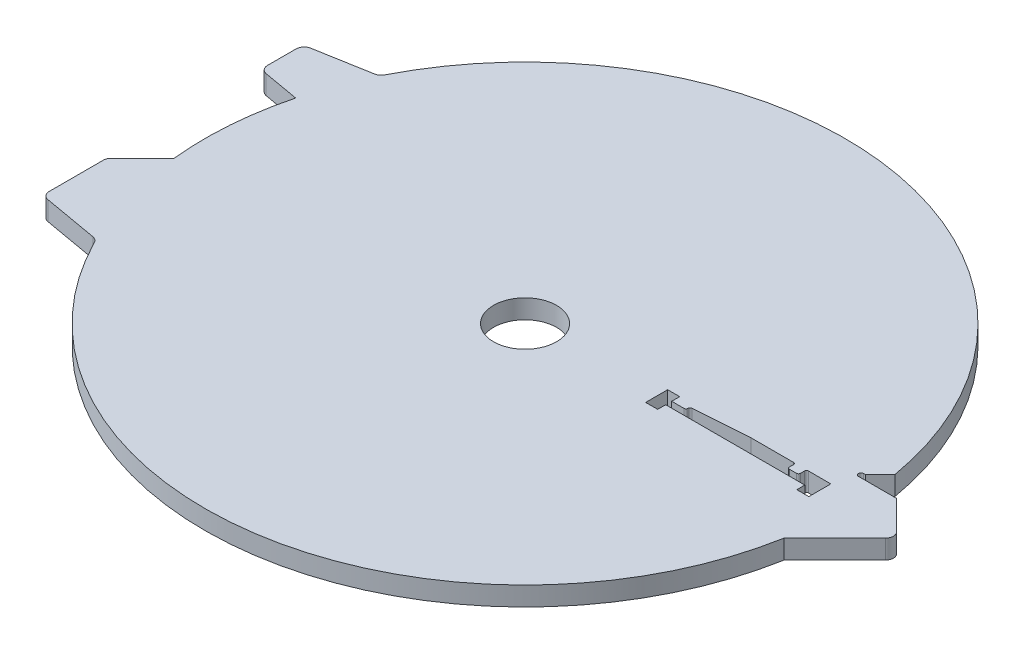
from build123d import *

# Parameters (mm, degrees)
SKETCH1_R           = 80
SKETCH1_R_2         = 7.875
BOSS_EXTRUDE1_DEPTH = 4.7625
CUT_EXTRUDE1_DEPTH  = 5.7625
BOSS_EXTRUDE2_DEPTH = 4.7625
CUT_EXTRUDE2_DEPTH  = 5.7625
CUT_EXTRUDE5_DEPTH  = 5.7625
FILLET1_R           = 2
SKETCH8_W           = 3
SKETCH8_H           = 5.5
CUT_EXTRUDE6_DEPTH  = 5.7625


with BuildPart() as part:
    # Sketch1 → Boss-Extrude1 (new body)
    with BuildSketch(Plane(origin=(0, 0, 0), x_dir=(1, 0, 0), z_dir=(0, 1, 0))):
        Circle(SKETCH1_R)
        Circle(SKETCH1_R_2, mode=Mode.SUBTRACT)
    extrude(amount=BOSS_EXTRUDE1_DEPTH)

    # Sketch2 → Cut-Extrude1 (cut, through all)
    with BuildSketch(Plane(origin=(0, 4.7625, 0), x_dir=(1, 0, 0), z_dir=(0, 1, 0))):
        with BuildLine():
            Line((34.2, 0), (70.8, 0))
            Line((70.8, 0), (70.8, 3))
            ThreePointArc((70.8, 3), (70.653553391, 3.353553391), (70.3, 3.5))
            Line((70.3, 3.5), (67.3, 3.5))
            ThreePointArc((67.3, 3.5), (66.946446609, 3.353553391), (66.8, 3))
            Line((66.8, 3), (66.8, 2))
            ThreePointArc((66.8, 2), (66.653553391, 1.646446609), (66.3, 1.5))
            Line((66.3, 1.5), (64.55, 1.5))
            ThreePointArc((64.55, 1.5), (64.196446609, 1.646446609), (64.05, 2))
            Line((64.05, 2), (64.05, 3))
            ThreePointArc((64.05, 3), (63.903553391, 3.353553391), (63.55, 3.5))
            Line((63.55, 3.5), (52.95, 3.5))
            Line((52.95, 3.5), (39.164998359, 2.532631464))
            ThreePointArc((39.164998359, 2.532631464), (38.834280968, 2.374812024), (38.7, 2.033858083))
            Line((38.7, 2.033858083), (38.7, 2))
            ThreePointArc((38.7, 2), (38.553553391, 1.646446609), (38.2, 1.5))
            Line((38.2, 1.5), (34.7, 1.5))
            ThreePointArc((34.7, 1.5), (34.346446609, 1.353553391), (34.2, 1))
            Line((34.2, 1), (34.2, 0))
        make_face()
    extrude(amount=-CUT_EXTRUDE1_DEPTH, mode=Mode.SUBTRACT)

    # Sketch4 → Boss-Extrude2 (add)
    with BuildSketch(Plane(origin=(0, 4.7625, 0), x_dir=(1, 0, 0), z_dir=(0, 1, 0))):
        Polygon((-88, 32.5), (-60, 37.43715546), (-60, -37.43715546), (-88, -32.5), (-88, -16.5), (-71.5, 0), (-88, 16.5), align=None)
        with BuildLine():
            Line((78.751819834, 14.076607291), (91.414213562, 1.414213562))
            ThreePointArc((91.414213562, 1.414213562), (92, 0), (91.414213562, -1.414213562))
            Line((91.414213562, -1.414213562), (78.751819834, -14.076607291))
            Line((78.751819834, -14.076607291), (78.751819834, 14.076607291))
        make_face()
    extrude(amount=-BOSS_EXTRUDE2_DEPTH)

    # Sketch3 → Cut-Extrude2 (cut, through all)
    with BuildSketch(Plane(origin=(0, 4.7625, 0), x_dir=(1, 0, 0), z_dir=(0, 1, 0))):
        with BuildLine():
            Line((75.187234449, 9.826135427), (74.687234449, 9.826135427))
            ThreePointArc((74.687234449, 9.826135427), (74.062234449, 9.201135427), (74.687234449, 8.576135427))
            Line((74.687234449, 8.576135427), (84.252291698, 8.576135427))
            Line((84.252291698, 8.576135427), (78.751819834, 14.076607291))
            ThreePointArc((78.751819834, 14.076607291), (78.803418829, 13.784817039), (78.853936691, 13.492837669))
            Line((78.853936691, 13.492837669), (75.187234449, 9.826135427))
        make_face()
    extrude(amount=-CUT_EXTRUDE2_DEPTH, mode=Mode.SUBTRACT)

    # Sketch7 → Cut-Extrude5 (cut, through all)
    with BuildSketch(Plane(origin=(0, 4.7625, 0), x_dir=(1, 0, 0), z_dir=(0, 1, 0))):
        with BuildLine():
            Line((-88, 22), (-77.424613279, 20.13527399))
            ThreePointArc((-77.424613279, 20.13527399), (-78.737936574, 14.154057514), (-79.589907619, 8.089907619))
            Line((-79.589907619, 8.089907619), (-88, 16.5))
            Line((-88, 16.5), (-88, 22))
        make_face()
    extrude(amount=-CUT_EXTRUDE5_DEPTH, mode=Mode.SUBTRACT)

    # Fillet1
    fillet1_edges = [part.edges().sort_by_distance(p)[0] for p in [
        (-88, 2.38125, -22),
        (-71.75940266, 2.38125, 35.363655494),
        (-71.75940266, 2.38125, -35.363655494),
        (-88, 2.38125, -32.5),
        (-88, 2.38125, 16.5),
        (-88, 2.38125, 32.5),
    ]]
    fillet(fillet1_edges, radius=FILLET1_R)

    # Sketch8 → Cut-Extrude6 (cut, through all)
    with BuildSketch(Plane(origin=(0, 4.7625, 0), x_dir=(1, 0, 0), z_dir=(0, 1, 0))):
        with Locations((33.625, 0.75)):
            Rectangle(SKETCH8_W, SKETCH8_H)
        with Locations((71.375, 0.75)):
            Rectangle(SKETCH8_W, SKETCH8_H)
    extrude(amount=-CUT_EXTRUDE6_DEPTH, mode=Mode.SUBTRACT)


solid = part.part
